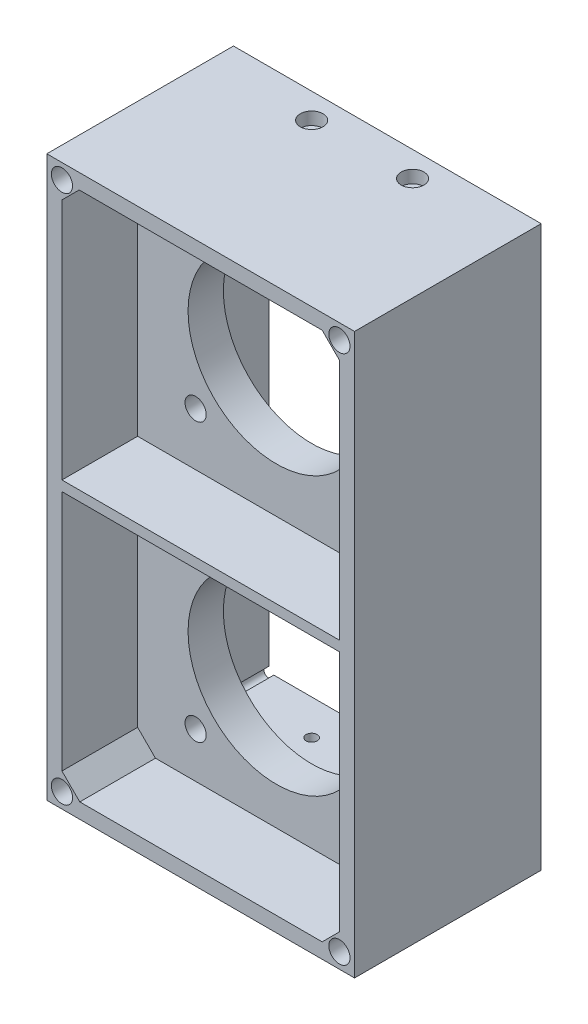
from build123d import *

# Parameters (mm, degrees)
SKETCH1_W           = 61
SKETCH1_H           = 111
SKETCH1_W_2         = 51
SKETCH1_H_2         = 101
BOSS_EXTRUDE1_DEPTH = 15
SKETCH2_W           = 61
SKETCH2_H           = 111
BOSS_EXTRUDE2_DEPTH = 7
SKETCH3_R           = 17.5
SKETCH3_R_2         = 1.75
CUT_EXTRUDE1_DEPTH  = 23
SKETCH4_R           = 2.1
CUT_EXTRUDE2_DEPTH  = 5
SKETCH5_W           = 55
SKETCH5_H           = 105
SKETCH5_W_2         = 51
SKETCH5_H_2         = 101
BOSS_EXTRUDE3_DEPTH = 2
FILLET1_R           = 1
SKETCH6_R           = 1.1
CUT_EXTRUDE3_DEPTH  = 112
SKETCH7_R           = 2.25
CUT_EXTRUDE4_DEPTH  = 2.5
SKETCH8_R           = 2.25
CUT_EXTRUDE5_DEPTH  = 2.5
CUT_EXTRUDE6_START  = -17
SKETCH9_R           = 1
CUT_EXTRUDE6_DEPTH  = 17
SKETCH10_W          = 61
SKETCH10_H          = 111
SKETCH10_W_2        = 55
SKETCH10_H_2        = 105
SKETCH10_H_3        = 2
BOSS_EXTRUDE4_DEPTH = 15
SKETCH11_R          = 2.1
CUT_EXTRUDE7_DEPTH  = 6


with BuildPart() as part:
    # Sketch1 → Boss-Extrude1 (new body)
    with BuildSketch(Plane.XY):
        with Locations((30.5, 55.5)):
            Rectangle(SKETCH1_W, SKETCH1_H)
        with Locations((30.5, 55.5)):
            Rectangle(SKETCH1_W_2, SKETCH1_H_2, mode=Mode.SUBTRACT)
    extrude(amount=BOSS_EXTRUDE1_DEPTH)

    # Sketch2 → Boss-Extrude2 (add)
    with BuildSketch(Plane.XY.offset(15)):
        with Locations((30.5, 55.5)):
            Rectangle(SKETCH2_W, SKETCH2_H)
    extrude(amount=BOSS_EXTRUDE2_DEPTH)

    # Sketch3 → Cut-Extrude1 (cut, through all)
    with BuildSketch(Plane.XY.offset(22)):
        with Locations((30.5, 83)):
            Circle(SKETCH3_R)
        with Locations((30.5, 28)):
            Circle(SKETCH3_R)
        with BuildLine():
            ThreePointArc((46.5, 13.75), (45.262563133, 13.237436867), (44.75, 12))
            Line((44.75, 12), (46.5, 12))
            Line((46.5, 12), (46.5, 13.75))
        make_face()
        with BuildLine():
            Line((46.5, 12), (44.75, 12))
            ThreePointArc((44.75, 12), (46.5, 10.25), (48.25, 12))
            ThreePointArc((48.25, 12), (47.737436867, 13.237436867), (46.5, 13.75))
            Line((46.5, 13.75), (46.5, 12))
        make_face()
        with Locations((46.5, 99)):
            Circle(SKETCH3_R_2)
        with Locations((14.5, 99)):
            Circle(SKETCH3_R_2)
        with Locations((14.5, 67)):
            Circle(SKETCH3_R_2)
        with Locations((46.5, 67)):
            Circle(SKETCH3_R_2)
        with Locations((46.5, 44)):
            Circle(SKETCH3_R_2)
        with Locations((14.5, 44)):
            Circle(SKETCH3_R_2)
        with Locations((14.5, 12)):
            Circle(SKETCH3_R_2)
    extrude(amount=-CUT_EXTRUDE1_DEPTH, mode=Mode.SUBTRACT)

    # Sketch4 → Cut-Extrude2 (cut)
    with BuildSketch(Plane.XY.offset(22)):
        with Locations((14.5, 99)):
            Circle(SKETCH4_R)
        with Locations((46.5, 99)):
            Circle(SKETCH4_R)
        with Locations((46.5, 67)):
            Circle(SKETCH4_R)
        with Locations((46.5, 44)):
            Circle(SKETCH4_R)
        with Locations((14.5, 67)):
            Circle(SKETCH4_R)
        with Locations((14.5, 44)):
            Circle(SKETCH4_R)
        with Locations((14.5, 12)):
            Circle(SKETCH4_R)
        with Locations((46.5, 12)):
            Circle(SKETCH4_R)
    extrude(amount=-CUT_EXTRUDE2_DEPTH, mode=Mode.SUBTRACT)

    # Sketch5 → Boss-Extrude3 (add)
    with BuildSketch(Plane(origin=(0, 0, 0), x_dir=(-1, 0, 0), z_dir=(0, 0, -1))):
        with Locations((-30.5, 55.5)):
            Rectangle(SKETCH5_W, SKETCH5_H)
        with Locations((-30.5, 55.5)):
            Rectangle(SKETCH5_W_2, SKETCH5_H_2, mode=Mode.SUBTRACT)
    extrude(amount=BOSS_EXTRUDE3_DEPTH)

    # Fillet1
    fillet1_edges = [part.edges().sort_by_distance(p)[0] for p in [
        (58, 3, -1),
        (3, 3, -1),
        (3, 108, -1),
        (58, 108, -1),
    ]]
    fillet(fillet1_edges, radius=FILLET1_R)

    # Sketch6 → Cut-Extrude3 (cut, through all)
    with BuildSketch(Plane(origin=(0, 0, 0), x_dir=(-1, 0, 0), z_dir=(0, -1, 0))):
        with Locations((-20.5, -5)):
            Circle(SKETCH6_R)
        with Locations((-40.5, -5)):
            Circle(SKETCH6_R)
    extrude(amount=-CUT_EXTRUDE3_DEPTH, mode=Mode.SUBTRACT)

    # Sketch7 → Cut-Extrude4 (cut)
    with BuildSketch(Plane.XZ):
        with Locations((20.5, 5)):
            Circle(SKETCH7_R)
        with Locations((40.5, 5)):
            Circle(SKETCH7_R)
    extrude(amount=-CUT_EXTRUDE4_DEPTH, mode=Mode.SUBTRACT)

    # Sketch8 → Cut-Extrude5 (cut)
    with BuildSketch(Plane(origin=(0, 111, 0), x_dir=(1, 0, 0), z_dir=(0, 1, 0))):
        with Locations((40.5, -5)):
            Circle(SKETCH8_R)
        with Locations((20.5, -5)):
            Circle(SKETCH8_R)
    extrude(amount=-CUT_EXTRUDE5_DEPTH, mode=Mode.SUBTRACT)

    # Sketch9 → Cut-Extrude6 (cut)
    with BuildSketch(Plane(origin=(0, 0, -2), x_dir=(-1, 0, 0), z_dir=(0, 0, -1)).offset(CUT_EXTRUDE6_START)):
        with Locations((-56, 106)):
            Circle(SKETCH9_R)
        with Locations((-5, 106)):
            Circle(SKETCH9_R)
        with Locations((-5, 5)):
            Circle(SKETCH9_R)
        with Locations((-56, 5)):
            Circle(SKETCH9_R)
    extrude(amount=CUT_EXTRUDE6_DEPTH, mode=Mode.SUBTRACT)

    # Sketch10 → Boss-Extrude4 (add)
    with BuildSketch(Plane.XY.offset(22)):
        with Locations((30.5, 55.5)):
            Rectangle(SKETCH10_W, SKETCH10_H)
        with Locations((30.5, 55.5)):
            Rectangle(SKETCH10_W_2, SKETCH10_H_2, mode=Mode.SUBTRACT)
        Polygon((3, 3), (6.535533906, 3), (3, 6.535533906), align=None)
        Polygon((3, 108), (3, 104.58049017), (6.41950983, 108), align=None)
        Polygon((54.58049017, 108), (58, 104.58049017), (58, 108), align=None)
        Polygon((58, 6.41950983), (54.58049017, 3), (58, 3), align=None)
        with Locations((30.5, 55.5)):
            Rectangle(SKETCH10_W_2, SKETCH10_H_3)
    extrude(amount=BOSS_EXTRUDE4_DEPTH)

    # Sketch11 → Cut-Extrude7 (cut)
    with BuildSketch(Plane.XY.offset(37)):
        with Locations((3, 3)):
            Circle(SKETCH11_R)
        with Locations((3, 108)):
            Circle(SKETCH11_R)
        with Locations((58, 108)):
            Circle(SKETCH11_R)
        with Locations((58, 3)):
            Circle(SKETCH11_R)
    extrude(amount=-CUT_EXTRUDE7_DEPTH, mode=Mode.SUBTRACT)


solid = part.part
